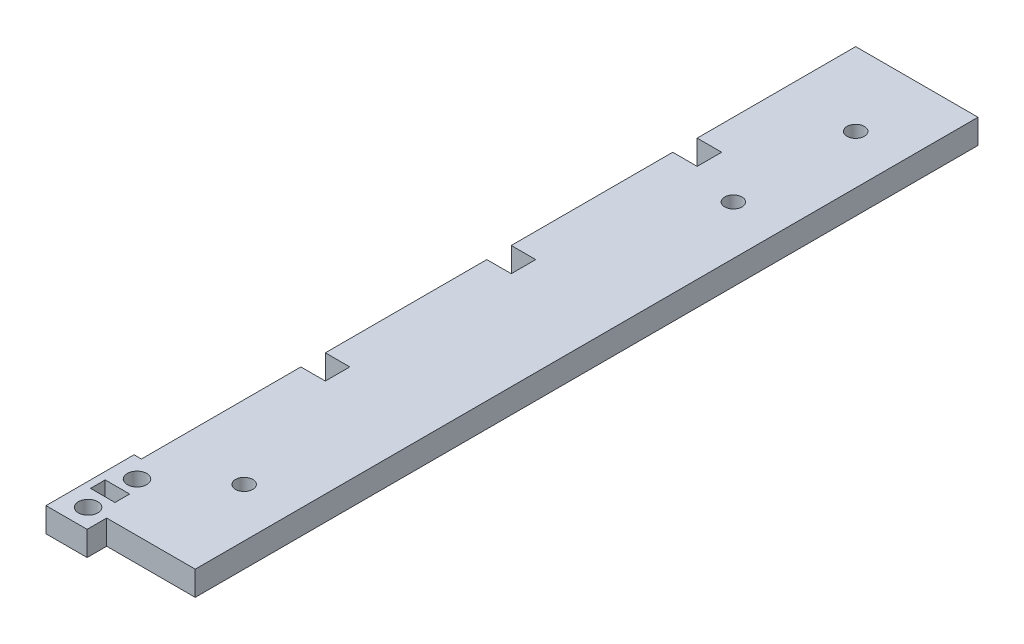
from build123d import *

# Parameters (mm, degrees)
BOSS_EXTRUDE1_DEPTH                                 = 6.35
SKETCH2_W                                           = 6.35
SKETCH2_H                                           = 6.35
CUT_EXTRUDE1_DEPTH                                  = 7.35
F_8_0_199_DIAMETER_HOLE1_D                          = 5.0546
SKETCH5_W                                           = 6.35
SKETCH5_H                                           = 3.81
CUT_EXTRUDE2_DEPTH                                  = 7.35
CBORE_FOR_8_BINDING_HEAD_MACHINE_SCREW1_D           = 4.4958
CBORE_FOR_8_BINDING_HEAD_MACHINE_SCREW1_CBORE_D     = 9.525
CBORE_FOR_8_BINDING_HEAD_MACHINE_SCREW1_CBORE_DEPTH = 3.175


with BuildPart() as part:
    # Sketch1 → Boss-Extrude1 (new body)
    with BuildSketch(Plane(origin=(0, 0, 0), x_dir=(1, 0, 0), z_dir=(0, 1, 0))):
        Polygon((8.763, -10.331391255), (8.763, -15.411391255), (-1.905, -15.411391255), (-1.905, 7.448608745), (0, 7.448608745), (0, 192.868608745), (31.75, 192.868608745), (31.75, -10.331391255), align=None)
    extrude(amount=BOSS_EXTRUDE1_DEPTH)

    # Sketch2 → Cut-Extrude1 (cut, through all)
    with BuildSketch(Plane(origin=(0, 6.35, 0), x_dir=(1, 0, 0), z_dir=(0, 1, 0))):
        with Locations((3.175, 52.025608745)):
            Rectangle(SKETCH2_W, SKETCH2_H)
        with Locations((3.175, 100.285608745)):
            Rectangle(SKETCH2_W, SKETCH2_H)
        with Locations((3.175, 148.545608745)):
            Rectangle(SKETCH2_W, SKETCH2_H)
    extrude(amount=-CUT_EXTRUDE1_DEPTH, mode=Mode.SUBTRACT)

    # #8 (0.199) Diameter Hole1 (through all)
    with Locations(Plane(origin=(0, 6.35, 0), x_dir=(1, 0, 0), z_dir=(0, 1, 0))):
        with Locations((3.937, 2.368608745), (3.937, -10.331391255)):
            Hole(F_8_0_199_DIAMETER_HOLE1_D / 2)

    # Sketch5 → Cut-Extrude2 (cut, through all)
    with BuildSketch(Plane(origin=(0, 6.35, 0), x_dir=(1, 0, 0), z_dir=(0, 1, 0))):
        with Locations((3.175, -3.854391255)):
            Rectangle(SKETCH5_W, SKETCH5_H)
    extrude(amount=-CUT_EXTRUDE2_DEPTH, mode=Mode.SUBTRACT)

    # CBORE for #8 Binding Head Machine Screw1 (through all)
    with Locations(Plane(origin=(0, 0, 0), x_dir=(-1, 0, 0), z_dir=(0, -1, 0))):
        with Locations((-19.05, 173.818608745), (-19.05, 142.068608745), (-19.05, 15.068608745)):
            CounterBoreHole(CBORE_FOR_8_BINDING_HEAD_MACHINE_SCREW1_D / 2, CBORE_FOR_8_BINDING_HEAD_MACHINE_SCREW1_CBORE_D / 2, CBORE_FOR_8_BINDING_HEAD_MACHINE_SCREW1_CBORE_DEPTH)


solid = part.part
